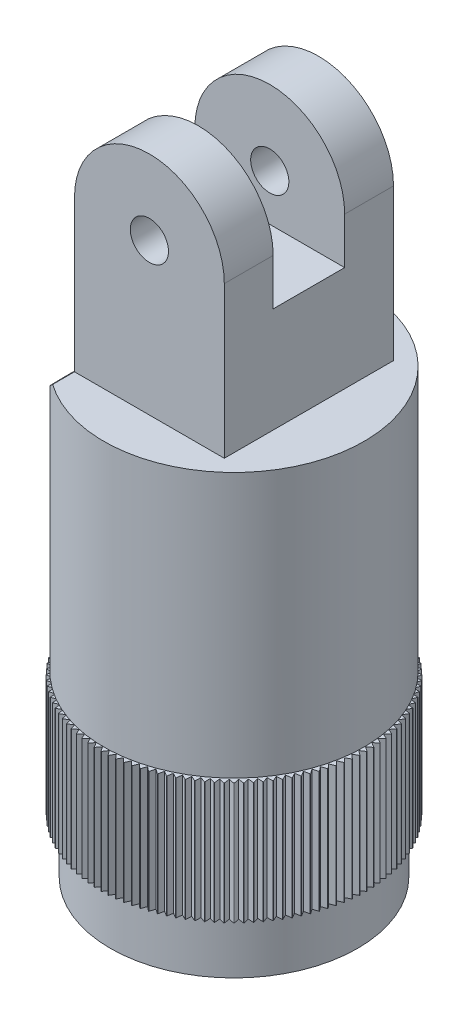
from build123d import *

# Parameters (mm, degrees)
BOSS_EXTRUDE1_START      = 2.8321
BOSS_EXTRUDE1_DEPTH      = 6.35
FILLET1_R                = 0.0127
CIRPATTERN2_COUNT        = 120
FILLET1_OF_CIRPATTERN2_R = 0.0127
CUT_EXTRUDE1_DEPTH       = 7.962238415
CUT_EXTRUDE1_DEPTH_BACK  = 7.962238415
SKETCH4_R                = 1
BOSS_EXTRUDE2_DEPTH      = 4.4323
SKETCH6_W                = 3.7465
SKETCH6_H                = 10.16
CUT_EXTRUDE2_DEPTH       = 7.962238415
CUT_EXTRUDE2_DEPTH_BACK  = 7.962238415


with BuildPart() as part:
    # Sketch1 → Revolve2 (revolve)
    with BuildSketch(Plane.XY):
        Polygon((-6.477, 9.1821), (-6.477, 0), (-2.77495, 0), (-2.77495, 5.5245), (-2.26695, 5.5245), (-2.26695, 2.9845), (-0.4699, 2.9845), (-0.4699, 15), (-3.048, 15), (-3.048, 9.1821), align=None)
    revolve(axis=Axis((0, 15, 0), (0, -1, 0)))

    # Sketch5 → Boss-Extrude1 (add)
    with BuildSketch(Plane(origin=(0, 0, 0), x_dir=(1, 0, 0), z_dir=(0, 1, 0)).offset(BOSS_EXTRUDE1_START)):
        with BuildLine():
            Line((-6.468123497, -0.338979989), (-6.9723, 0))
            Line((-6.9723, 0), (-6.468123497, 0.338979989))
            ThreePointArc((-6.468123497, 0.338979989), (-6.477, 0), (-6.468123497, -0.338979989))
        make_face()
    boss_extrude1 = extrude(amount=BOSS_EXTRUDE1_DEPTH)

    # Fillet1
    fillet1_edges = [part.edges().sort_by_distance(p)[0] for p in [
        (-6.9723, 6.0071, 0),
    ]]
    fillet(fillet1_edges, radius=FILLET1_R)

    # CirPattern2: Boss-Extrude1 ×120 about axis
    cirpattern2_axis = Axis((0, 0, 0), (0, 1, 0))
    for i in range(1, CIRPATTERN2_COUNT):
        add(boss_extrude1.rotate(cirpattern2_axis, i * 360 / CIRPATTERN2_COUNT))

    # Fillet1 of CirPattern2
    fillet1_of_cirpattern2_edges = [part.edges().sort_by_distance(p)[0] for p in [
        (-6.962744705, 6.0071, 0.364901988),
        (-6.934105011, 6.0071, 0.728803804),
        (-6.886459417, 6.0071, 1.090708021),
        (-6.819938517, 6.0071, 1.449622682),
        (-6.734724639, 6.0071, 1.804564028),
        (-6.631051349, 6.0071, 2.15455919),
        (-6.509202808, 6.0071, 2.498648855),
        (-6.369512994, 6.0071, 2.835889897),
        (-6.212364789, 6.0071, 3.165357961),
        (-6.038188923, 6.0071, 3.48615),
        (-5.847462801, 6.0071, 3.797386744),
        (-5.64070919, 6.0071, 4.098215115),
        (-5.418494787, 6.0071, 4.387810563),
        (-5.181428667, 6.0071, 4.665379327),
        (-4.93016061, 6.0071, 4.93016061),
        (-4.665379327, 6.0071, 5.181428667),
        (-4.387810563, 6.0071, 5.418494787),
        (-4.098215115, 6.0071, 5.64070919),
        (-3.797386744, 6.0071, 5.847462801),
        (-3.48615, 6.0071, 6.038188923),
        (-3.165357961, 6.0071, 6.212364789),
        (-2.835889897, 6.0071, 6.369512994),
        (-2.498648855, 6.0071, 6.509202808),
        (-2.15455919, 6.0071, 6.631051349),
        (-1.804564028, 6.0071, 6.734724639),
        (-1.449622682, 6.0071, 6.819938517),
        (-1.090708021, 6.0071, 6.886459417),
        (-0.728803804, 6.0071, 6.934105011),
        (-0.364901988, 6.0071, 6.962744705),
        (0, 6.0071, 6.9723),
        (0.364901988, 6.0071, 6.962744705),
        (0.728803804, 6.0071, 6.934105011),
        (1.090708021, 6.0071, 6.886459417),
        (1.449622682, 6.0071, 6.819938517),
        (1.804564028, 6.0071, 6.734724639),
        (2.15455919, 6.0071, 6.631051349),
        (2.498648855, 6.0071, 6.509202808),
        (2.835889897, 6.0071, 6.369512994),
        (3.165357961, 6.0071, 6.212364789),
        (3.48615, 6.0071, 6.038188923),
        (3.797386744, 6.0071, 5.847462801),
        (4.098215115, 6.0071, 5.64070919),
        (4.387810563, 6.0071, 5.418494787),
        (4.665379327, 6.0071, 5.181428667),
        (4.93016061, 6.0071, 4.93016061),
        (5.181428667, 6.0071, 4.665379327),
        (5.418494787, 6.0071, 4.387810563),
        (5.64070919, 6.0071, 4.098215115),
        (5.847462801, 6.0071, 3.797386744),
        (6.038188923, 6.0071, 3.48615),
        (6.212364789, 6.0071, 3.165357961),
        (6.369512994, 6.0071, 2.835889897),
        (6.509202808, 6.0071, 2.498648855),
        (6.631051349, 6.0071, 2.15455919),
        (6.734724639, 6.0071, 1.804564028),
        (6.819938517, 6.0071, 1.449622682),
        (6.886459417, 6.0071, 1.090708021),
        (6.934105011, 6.0071, 0.728803804),
        (6.962744705, 6.0071, 0.364901988),
        (6.9723, 6.0071, 0),
        (6.962744705, 6.0071, -0.364901988),
        (6.934105011, 6.0071, -0.728803804),
        (6.886459417, 6.0071, -1.090708021),
        (6.819938517, 6.0071, -1.449622682),
        (6.734724639, 6.0071, -1.804564028),
        (6.631051349, 6.0071, -2.15455919),
        (6.509202808, 6.0071, -2.498648855),
        (6.369512994, 6.0071, -2.835889897),
        (6.212364789, 6.0071, -3.165357961),
        (6.038188923, 6.0071, -3.48615),
        (5.847462801, 6.0071, -3.797386744),
        (5.64070919, 6.0071, -4.098215115),
        (5.418494787, 6.0071, -4.387810563),
        (5.181428667, 6.0071, -4.665379327),
        (4.93016061, 6.0071, -4.93016061),
        (4.665379327, 6.0071, -5.181428667),
        (4.387810563, 6.0071, -5.418494787),
        (4.098215115, 6.0071, -5.64070919),
        (3.797386744, 6.0071, -5.847462801),
        (3.48615, 6.0071, -6.038188923),
        (3.165357961, 6.0071, -6.212364789),
        (2.835889897, 6.0071, -6.369512994),
        (2.498648855, 6.0071, -6.509202808),
        (2.15455919, 6.0071, -6.631051349),
        (1.804564028, 6.0071, -6.734724639),
        (1.449622682, 6.0071, -6.819938517),
        (1.090708021, 6.0071, -6.886459417),
        (0.728803804, 6.0071, -6.934105011),
        (0.364901988, 6.0071, -6.962744705),
        (0, 6.0071, -6.9723),
        (-0.364901988, 6.0071, -6.962744705),
        (-0.728803804, 6.0071, -6.934105011),
        (-1.090708021, 6.0071, -6.886459417),
        (-1.449622682, 6.0071, -6.819938517),
        (-1.804564028, 6.0071, -6.734724639),
        (-2.15455919, 6.0071, -6.631051349),
        (-2.498648855, 6.0071, -6.509202808),
        (-2.835889897, 6.0071, -6.369512994),
        (-3.165357961, 6.0071, -6.212364789),
        (-3.48615, 6.0071, -6.038188923),
        (-3.797386744, 6.0071, -5.847462801),
        (-4.098215115, 6.0071, -5.64070919),
        (-4.387810563, 6.0071, -5.418494787),
        (-4.665379327, 6.0071, -5.181428667),
        (-4.93016061, 6.0071, -4.93016061),
        (-5.181428667, 6.0071, -4.665379327),
        (-5.418494787, 6.0071, -4.387810563),
        (-5.64070919, 6.0071, -4.098215115),
        (-5.847462801, 6.0071, -3.797386744),
        (-6.038188923, 6.0071, -3.48615),
        (-6.212364789, 6.0071, -3.165357961),
        (-6.369512994, 6.0071, -2.835889897),
        (-6.509202808, 6.0071, -2.498648855),
        (-6.631051349, 6.0071, -2.15455919),
        (-6.734724639, 6.0071, -1.804564028),
        (-6.819938517, 6.0071, -1.449622682),
        (-6.886459417, 6.0071, -1.090708021),
        (-6.934105011, 6.0071, -0.728803804),
        (-6.962744705, 6.0071, -0.364901988),
    ]]
    fillet(fillet1_of_cirpattern2_edges, radius=FILLET1_OF_CIRPATTERN2_R)


with BuildPart() as body_2:
    # Sketch2 → Revolve1 (revolve)
    with BuildSketch(Plane.XY):
        Polygon((-6.8199, 9.3091), (-3.175, 9.3091), (-3.175, 15.127), (-0.4699, 15.127), (-0.4699, 23.1775), (-6.8199, 23.1775), align=None)
    revolve(axis=Axis((0, 15, 0), (0, 1, 0)))

    # Sketch3 → Cut-Extrude1 (cut, two sides)
    with BuildSketch(Plane.XY) as cut_extrude1_sk:
        Polygon((-3.9243, 23.1775), (-6.8199, 20.32), (-6.8199, 23.1775), align=None)
    extrude(amount=CUT_EXTRUDE1_DEPTH, mode=Mode.SUBTRACT)
    extrude(cut_extrude1_sk.sketch, amount=-CUT_EXTRUDE1_DEPTH_BACK, mode=Mode.SUBTRACT)

    # Sketch4 → Boss-Extrude2 (add, symmetric)
    with BuildSketch(Plane.XY):
        with BuildLine():
            Line((-3.9243, 23.1775), (-3.9243, 31.1023))
            ThreePointArc((-3.9243, 31.1023), (0, 35.0266), (3.9243, 31.1023))
            Line((3.9243, 31.1023), (3.9243, 23.1775))
            Line((3.9243, 23.1775), (-3.9243, 23.1775))
        make_face()
        with Locations((0, 31.1023)):
            Circle(SKETCH4_R, mode=Mode.SUBTRACT)
    extrude(amount=BOSS_EXTRUDE2_DEPTH, both=True)

    # Sketch6 → Cut-Extrude2 (cut, two sides)
    with BuildSketch(Plane(origin=(0, 0, 0), x_dir=(0, 0, -1), z_dir=(1, 0, 0))) as cut_extrude2_sk:
        with Locations((0, 33.7566)):
            Rectangle(SKETCH6_W, SKETCH6_H)
    extrude(amount=CUT_EXTRUDE2_DEPTH, mode=Mode.SUBTRACT)
    extrude(cut_extrude2_sk.sketch, amount=-CUT_EXTRUDE2_DEPTH_BACK, mode=Mode.SUBTRACT)


solid = Compound([part.part, body_2.part])
